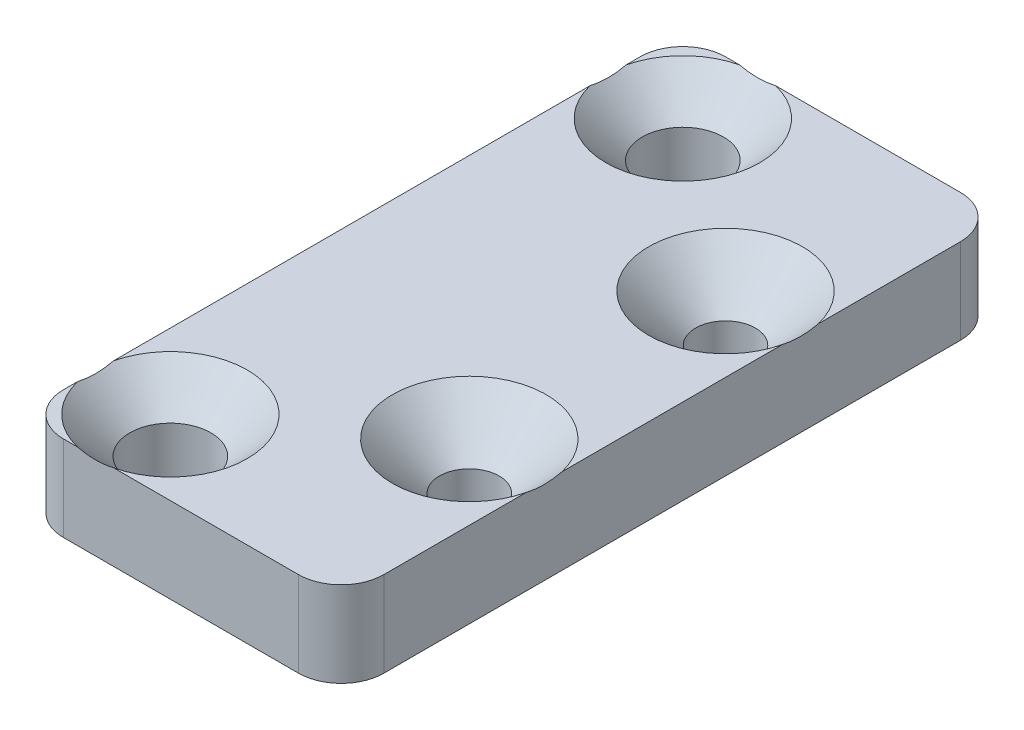
from build123d import *

# Parameters (mm, degrees)
SKETCH1_R                                       = 0.95
SKETCH1_R_2                                     = 0.7
BOSS_EXTRUDE1_DEPTH                             = 2
CSK_FOR_M2_FLAT_HEAD_MACHINE_SCREW1_D           = 1.4
CSK_FOR_M2_FLAT_HEAD_MACHINE_SCREW1_CSINK_D     = 3.6
CSK_FOR_M2_FLAT_HEAD_MACHINE_SCREW1_CSINK_ANGLE = 90


with BuildPart() as part:
    # Sketch1 → Boss-Extrude1 (new body)
    with BuildSketch(Plane(origin=(0, 0, 0), x_dir=(1, 0, 0), z_dir=(0, 1, 0))):
        with BuildLine():
            Line((-2.75, 7.75), (2.75, 7.75))
            ThreePointArc((2.75, 7.75), (3.457106781, 7.457106781), (3.75, 6.75))
            Line((3.75, 6.75), (3.75, -6.75))
            ThreePointArc((3.75, -6.75), (3.457106781, -7.457106781), (2.75, -7.75))
            Line((2.75, -7.75), (-2.75, -7.75))
            ThreePointArc((-2.75, -7.75), (-3.457106781, -7.457106781), (-3.75, -6.75))
            Line((-3.75, -6.75), (-3.75, 6.75))
            ThreePointArc((-3.75, 6.75), (-3.457106781, 7.457106781), (-2.75, 7.75))
        make_face()
        with Locations((-2, 6)):
            Circle(SKETCH1_R, mode=Mode.SUBTRACT)
        with Locations((-2, -6)):
            Circle(SKETCH1_R, mode=Mode.SUBTRACT)
        with Locations((2, 3)):
            Circle(SKETCH1_R_2, mode=Mode.SUBTRACT)
        with Locations((2, -3)):
            Circle(SKETCH1_R_2, mode=Mode.SUBTRACT)
    extrude(amount=BOSS_EXTRUDE1_DEPTH)

    # CSK for M2 Flat Head Machine Screw1 (through all)
    with Locations(Plane(origin=(-2, 2, 6), x_dir=(0, 0, 1), z_dir=(0, 1, 0))):
        with Locations((0, 0), (-12, 0), (-3, 4), (-9, 4)):
            CounterSinkHole(CSK_FOR_M2_FLAT_HEAD_MACHINE_SCREW1_D / 2, CSK_FOR_M2_FLAT_HEAD_MACHINE_SCREW1_CSINK_D / 2, counter_sink_angle=CSK_FOR_M2_FLAT_HEAD_MACHINE_SCREW1_CSINK_ANGLE)


solid = part.part
